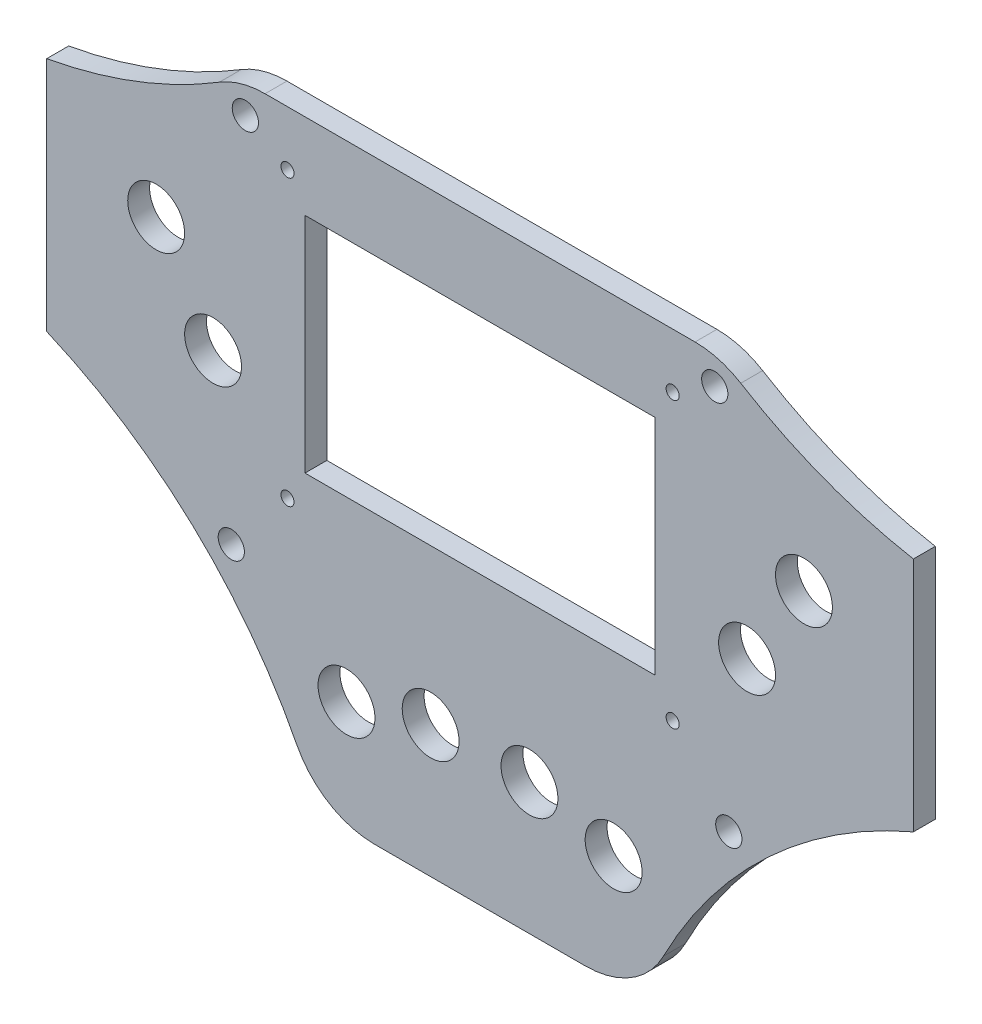
from build123d import *

# Parameters (mm, degrees)
ESBO_O1_R                = 6.5
ESBO_O1_R_2              = 3
ESBO_O1_R_3              = 1.5
ESBO_O1_W                = 80
ESBO_O1_H                = 51
RESSALTO_EXTRUS_O1_DEPTH = 5


with BuildPart() as part:
    # Esboço1 → Ressalto-extrusão1 (new body)
    with BuildSketch(Plane.XY):
        with BuildLine():
            Line((-49.119135606, 68), (49.119135606, 68))
            ThreePointArc((49.119135606, 68), (54.543435225, 67.250375935), (59.56111629, 65.057697365))
            ThreePointArc((59.56111629, 65.057697365), (78.583692726, 55.703629757), (99, 50))
            Line((99, 50), (99, -4))
            ThreePointArc((99, -4), (65.800143376, -25.584477196), (41.890064111, -57.150728877))
            ThreePointArc((41.890064111, -57.150728877), (34.522230169, -65.073584532), (24.106246719, -68))
            Line((24.106246719, -68), (-24.106246719, -68))
            ThreePointArc((-24.106246719, -68), (-34.522230169, -65.073584532), (-41.890064111, -57.150728877))
            ThreePointArc((-41.890064111, -57.150728877), (-65.800143376, -25.584477196), (-99, -4))
            Line((-99, -4), (-99, 50))
            ThreePointArc((-99, 50), (-78.583692726, 55.703629757), (-59.56111629, 65.057697365))
            ThreePointArc((-59.56111629, 65.057697365), (-54.543435225, 67.250375935), (-49.119135606, 68))
        make_face()
        with Locations((74, 31.167626134)):
            Circle(ESBO_O1_R, mode=Mode.SUBTRACT)
        with Locations((61, 11.261041117)):
            Circle(ESBO_O1_R, mode=Mode.SUBTRACT)
        with Locations((11.289140568, -38)):
            Circle(ESBO_O1_R, mode=Mode.SUBTRACT)
        with Locations((30.514158569, -43)):
            Circle(ESBO_O1_R, mode=Mode.SUBTRACT)
        with Locations((-53.62430165, 61.446355775)):
            Circle(ESBO_O1_R_2, mode=Mode.SUBTRACT)
        with Locations((-56.834913612, -25.028841797)):
            Circle(ESBO_O1_R_2, mode=Mode.SUBTRACT)
        with Locations((-44, 55.5)):
            Circle(ESBO_O1_R_3, mode=Mode.SUBTRACT)
        with Locations((-44, -9.5)):
            Circle(ESBO_O1_R_3, mode=Mode.SUBTRACT)
        with Locations((44, -9.5)):
            Circle(ESBO_O1_R_3, mode=Mode.SUBTRACT)
        with Locations((44, 55.5)):
            Circle(ESBO_O1_R_3, mode=Mode.SUBTRACT)
        with Locations((56.834913612, -25.028841797)):
            Circle(ESBO_O1_R_2, mode=Mode.SUBTRACT)
        with Locations((-30.514158569, -43)):
            Circle(ESBO_O1_R, mode=Mode.SUBTRACT)
        with Locations((-11.289140568, -38)):
            Circle(ESBO_O1_R, mode=Mode.SUBTRACT)
        with Locations((-61, 11.261041117)):
            Circle(ESBO_O1_R, mode=Mode.SUBTRACT)
        with Locations((53.62430165, 61.446355775)):
            Circle(ESBO_O1_R_2, mode=Mode.SUBTRACT)
        with Locations((-74, 31.167626134)):
            Circle(ESBO_O1_R, mode=Mode.SUBTRACT)
        with Locations((0, 23)):
            Rectangle(ESBO_O1_W, ESBO_O1_H, mode=Mode.SUBTRACT)
    extrude(amount=RESSALTO_EXTRUS_O1_DEPTH)


solid = part.part
